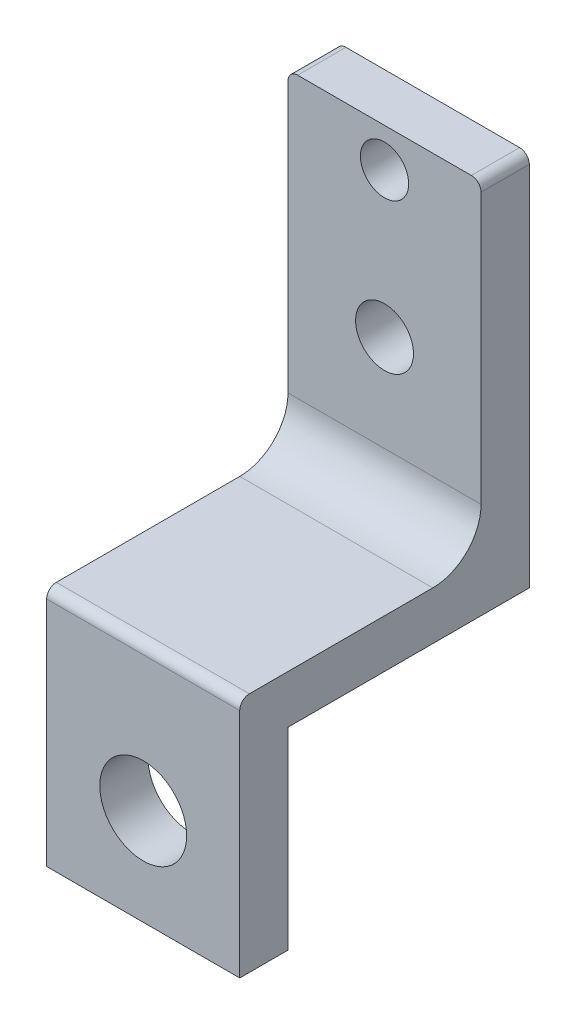
from build123d import *

# Parameters (mm, degrees)
SKETCH1_R           = 4.5
BOSS_EXTRUDE1_DEPTH = 5
SKETCH2_W           = 20
SKETCH2_H           = 39
BOSS_EXTRUDE2_DEPTH = 25
CUT_EXTRUDE1_DEPTH  = 30
SKETCH4_R           = 2.5
SKETCH4_R_2         = 3
CUT_EXTRUDE2_DEPTH  = 30
FILLET1_R           = 5
FILLET2_R           = 1


with BuildPart() as part:
    # Sketch1 → Boss-Extrude1 (new body)
    with BuildSketch(Plane.XY):
        Polygon((-10, 10), (-10, -10), (10, -10), (10, 10), (10, 49), (-10, 49), align=None)
        Circle(SKETCH1_R, mode=Mode.SUBTRACT)
    extrude(amount=BOSS_EXTRUDE1_DEPTH)

    # Sketch2 → Boss-Extrude2 (add)
    with BuildSketch(Plane(origin=(0, 0, 0), x_dir=(-1, 0, 0), z_dir=(0, 0, -1))):
        with Locations((0, 29.5)):
            Rectangle(SKETCH2_W, SKETCH2_H)
    extrude(amount=BOSS_EXTRUDE2_DEPTH)

    # Sketch3 → Cut-Extrude1 (cut)
    with BuildSketch(Plane(origin=(10, 0, 0), x_dir=(0, 0, -1), z_dir=(1, 0, 0))):
        Polygon((0, 15), (-5, 15), (-5, 49), (20, 49), (20, 15), align=None)
    extrude(amount=-CUT_EXTRUDE1_DEPTH, mode=Mode.SUBTRACT)

    # Sketch4 → Cut-Extrude2 (cut)
    with BuildSketch(Plane.XY.offset(-20)):
        with Locations((0, 45)):
            Circle(SKETCH4_R)
        with Locations((0, 30)):
            Circle(SKETCH4_R_2)
    extrude(amount=-CUT_EXTRUDE2_DEPTH, mode=Mode.SUBTRACT)

    # Fillet1
    fillet1_edges = [part.edges().sort_by_distance(p)[0] for p in [
        (0, 15, -20),
    ]]
    fillet(fillet1_edges, radius=FILLET1_R)

    # Fillet2
    fillet2_edges = [part.edges().sort_by_distance(p)[0] for p in [
        (-10, 49, -22.5),
        (10, 49, -22.5),
        (0, 15, 5),
    ]]
    fillet(fillet2_edges, radius=FILLET2_R)


solid = part.part
